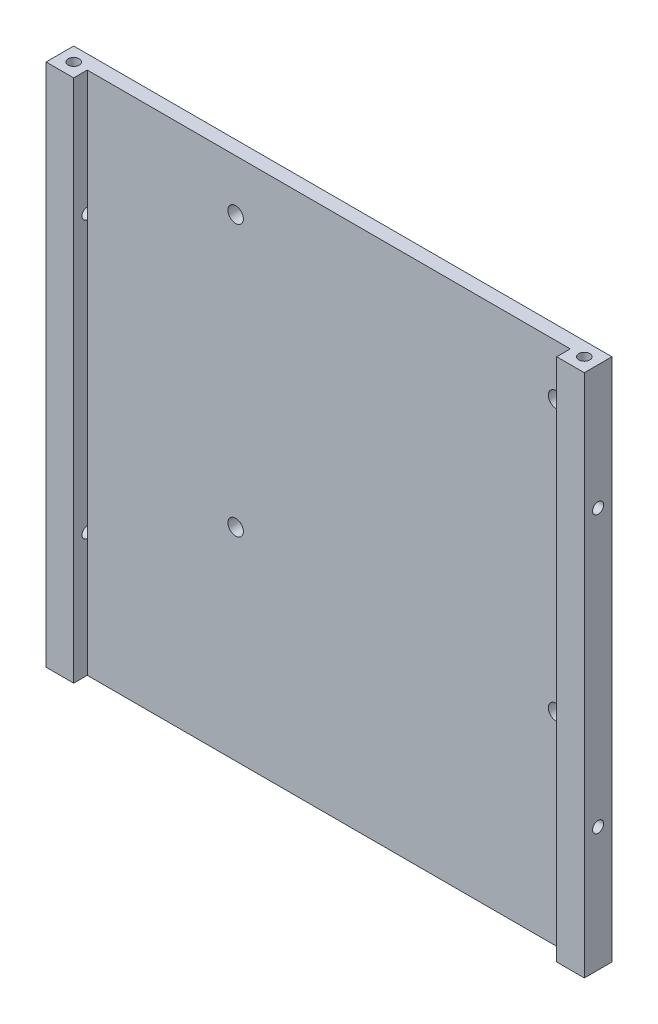
from build123d import *

# Parameters (mm, degrees)
SKETCH1_W           = 97.46
SKETCH1_H           = 97.46
BOSS_EXTRUDE1_DEPTH = 1.27
SKETCH3_W           = 5
SKETCH3_H           = 97.46
BOSS_EXTRUDE2_DEPTH = 3.73
SKETCH7_R           = 1
CUT_EXTRUDE2_DEPTH  = 5
SKETCH6_R           = 1
CUT_EXTRUDE3_DEPTH  = 5
SKETCH4_R           = 1
CUT_EXTRUDE4_DEPTH  = 5
SKETCH5_R           = 1
CUT_EXTRUDE5_DEPTH  = 5
CUT_EXTRUDE7_REACH  = 99.46
SKETCH10_R          = 1
CUT_EXTRUDE8_REACH  = 99.46
SKETCH9_R           = 1
CUT_EXTRUDE9_DEPTH  = 1.27
CUT_EXTRUDE10_DEPTH = 1.27
SKETCH13_W          = 87.46
SKETCH13_H          = 94.92
BOSS_EXTRUDE3_DEPTH = 1.27
SKETCH8_R           = 1.4
CUT_EXTRUDE6_DEPTH  = 10


with BuildPart() as part:
    # Sketch1 → Boss-Extrude1 (new body)
    with BuildSketch(Plane.XY):
        with Locations((48.73, 48.73)):
            Rectangle(SKETCH1_W, SKETCH1_H)
    extrude(amount=BOSS_EXTRUDE1_DEPTH)

    # Sketch3 → Boss-Extrude2 (add)
    with BuildSketch(Plane.XY.offset(1.27)):
        with Locations((2.5, 48.73)):
            Rectangle(SKETCH3_W, SKETCH3_H)
        with Locations((94.96, 48.73)):
            Rectangle(SKETCH3_W, SKETCH3_H)
    extrude(amount=BOSS_EXTRUDE2_DEPTH)

    # Sketch7 → Cut-Extrude2 (cut)
    with BuildSketch(Plane(origin=(0, 97.46, 0), x_dir=(-1, 0, 0), z_dir=(0, 1, 0))):
        with Locations((-2.5, 2.5)):
            Circle(SKETCH7_R)
    extrude(amount=-CUT_EXTRUDE2_DEPTH, mode=Mode.SUBTRACT)

    # Sketch6 → Cut-Extrude3 (cut)
    with BuildSketch(Plane(origin=(0, 97.46, 0), x_dir=(-1, 0, 0), z_dir=(0, 1, 0))):
        with Locations((-94.96, 2.5)):
            Circle(SKETCH6_R)
    extrude(amount=-CUT_EXTRUDE3_DEPTH, mode=Mode.SUBTRACT)

    # Sketch4 → Cut-Extrude4 (cut)
    with BuildSketch(Plane.XZ):
        with Locations((94.96, 2.5)):
            Circle(SKETCH4_R)
    extrude(amount=-CUT_EXTRUDE4_DEPTH, mode=Mode.SUBTRACT)

    # Sketch5 → Cut-Extrude5 (cut)
    with BuildSketch(Plane.XZ):
        with Locations((2.5, 2.5)):
            Circle(SKETCH5_R)
    extrude(amount=-CUT_EXTRUDE5_DEPTH, mode=Mode.SUBTRACT)

    # Sketch10 → Cut-Extrude7 (cut, up to next)
    with BuildSketch(Plane.ZY, mode=Mode.PRIVATE) as cut_extrude7_sk1:
        with Locations((2.5, 23.73)):
            Circle(SKETCH10_R)
    cut_extrude7_tool1 = extrude(cut_extrude7_sk1.sketch, amount=-CUT_EXTRUDE7_REACH, mode=Mode.PRIVATE) & part.part
    add(cut_extrude7_tool1.solids().sort_by_distance((0, 23.73, 2.5))[0], mode=Mode.SUBTRACT)
    # Sketch10 → Cut-Extrude7 (cut, up to next)
    with BuildSketch(Plane.ZY, mode=Mode.PRIVATE) as cut_extrude7_sk2:
        with Locations((2.5, 73.73)):
            Circle(SKETCH10_R)
    cut_extrude7_tool2 = extrude(cut_extrude7_sk2.sketch, amount=-CUT_EXTRUDE7_REACH, mode=Mode.PRIVATE) & part.part
    add(cut_extrude7_tool2.solids().sort_by_distance((0, 73.73, 2.5))[0], mode=Mode.SUBTRACT)

    # Sketch9 → Cut-Extrude8 (cut, up to next)
    with BuildSketch(Plane(origin=(97.46, 0, 0), x_dir=(0, 0, -1), z_dir=(1, 0, 0)), mode=Mode.PRIVATE) as cut_extrude8_sk1:
        with Locations((-2.5, 73.73)):
            Circle(SKETCH9_R)
    cut_extrude8_tool1 = extrude(cut_extrude8_sk1.sketch, amount=-CUT_EXTRUDE8_REACH, mode=Mode.PRIVATE) & part.part
    add(cut_extrude8_tool1.solids().sort_by_distance((97.46, 73.73, 2.5))[0], mode=Mode.SUBTRACT)
    # Sketch9 → Cut-Extrude8 (cut, up to next)
    with BuildSketch(Plane(origin=(97.46, 0, 0), x_dir=(0, 0, -1), z_dir=(1, 0, 0)), mode=Mode.PRIVATE) as cut_extrude8_sk2:
        with Locations((-2.5, 23.73)):
            Circle(SKETCH9_R)
    cut_extrude8_tool2 = extrude(cut_extrude8_sk2.sketch, amount=-CUT_EXTRUDE8_REACH, mode=Mode.PRIVATE) & part.part
    add(cut_extrude8_tool2.solids().sort_by_distance((97.46, 23.73, 2.5))[0], mode=Mode.SUBTRACT)

    # Sketch11 → Cut-Extrude9 (cut)
    with BuildSketch(Plane(origin=(0, 0, 0), x_dir=(-1, 0, 0), z_dir=(0, -1, 0))):
        Polygon((-92.46, -5), (-97.46, -5), (-97.46, 0), (0, 0), (0, -5), (-5, -5), (-5, -1.27), (-92.46, -1.27), align=None)
    extrude(amount=-CUT_EXTRUDE9_DEPTH, mode=Mode.SUBTRACT)

    # Sketch12 → Cut-Extrude10 (cut)
    with BuildSketch(Plane(origin=(0, 97.46, 0), x_dir=(1, 0, 0), z_dir=(0, 1, 0))):
        Polygon((92.46, -1.27), (92.46, -5), (97.46, -5), (97.46, 0), (0, 0), (0, -5), (5, -5), (5, -1.27), align=None)
    extrude(amount=-CUT_EXTRUDE10_DEPTH, mode=Mode.SUBTRACT)

    # Sketch13 → Boss-Extrude3 (add)
    with BuildSketch(Plane.XY.offset(1.27)):
        with Locations((48.73, 48.73)):
            Rectangle(SKETCH13_W, SKETCH13_H)
    extrude(amount=BOSS_EXTRUDE3_DEPTH)

    # Sketch8 → Cut-Extrude6 (cut)
    with BuildSketch(Plane(origin=(0, 0, 0), x_dir=(-1, 0, 0), z_dir=(0, 0, -1))):
        with Locations((-31.864061653, 37.943406611)):
            Circle(SKETCH8_R)
        with Locations((-89.874061653, 86.953406611)):
            Circle(SKETCH8_R)
        with Locations((-31.864061653, 86.953406611)):
            Circle(SKETCH8_R)
        with Locations((-89.874061653, 37.943406611)):
            Circle(SKETCH8_R)
    extrude(amount=-CUT_EXTRUDE6_DEPTH, mode=Mode.SUBTRACT)


solid = part.part
